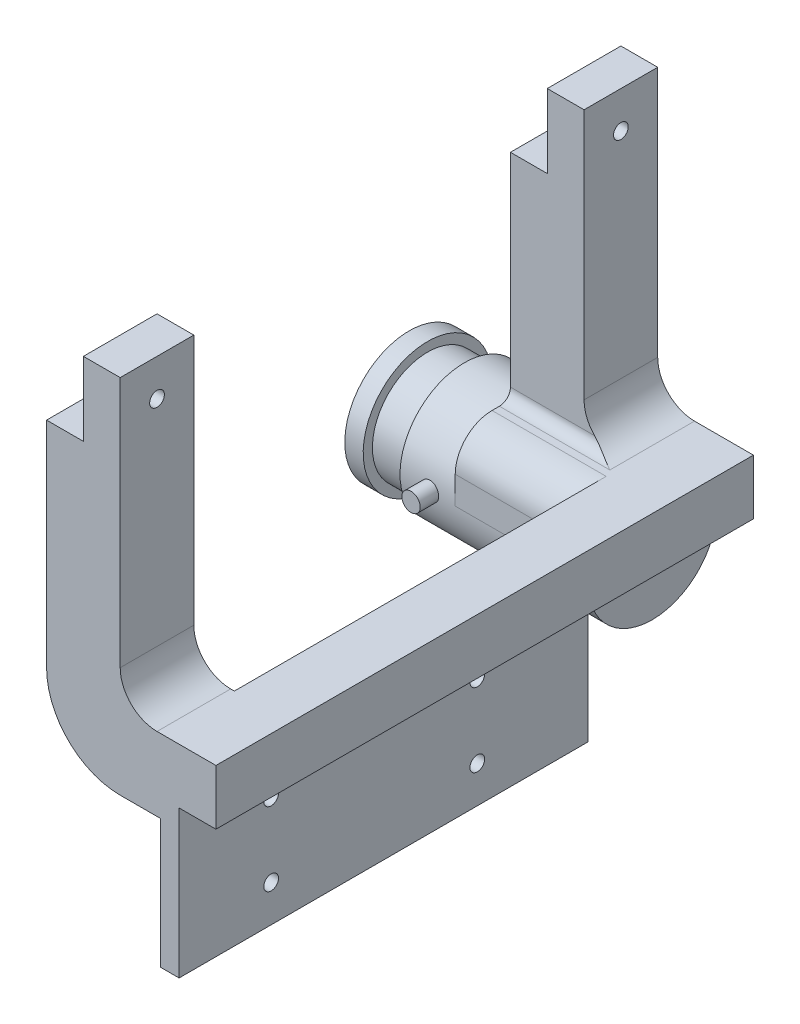
from build123d import *

# Parameters (mm, degrees)
BOSS_EXTRUDE3_DEPTH              = 10
SKETCH8_W                        = 146
SKETCH8_H                        = 15
BOSS_EXTRUDE6_DEPTH              = 5
SKETCH9_W                        = 5
SKETCH9_H                        = 146
BOSS_EXTRUDE7_DEPTH              = 20
BOSS_EXTRUDE8_DEPTH              = 20
SKETCH17_W                       = 20
SKETCH17_H                       = 20
CUT_EXTRUDE4_DEPTH               = 10
SKETCH18_R                       = 2
CUT_EXTRUDE5_DEPTH               = 10
SKETCH20_W                       = 35
SKETCH20_H                       = 35
BOSS_EXTRUDE9_DEPTH              = 31
SKETCH21_R                       = 17.5
BOSS_EXTRUDE10_DEPTH             = 30
CUT_EXTRUDE6_DEPTH               = 31
FILLET1_R                        = 3
SKETCH26_R                       = 17.5
SKETCH26_R_2                     = 15
CUT_EXTRUDE9_DEPTH               = 10
FILLET2_R                        = 10
SKETCH27_W                       = 5
SKETCH27_H                       = 146
BOSS_EXTRUDE11_DEPTH             = 20
SKETCH28_W                       = 10
SKETCH28_H                       = 126
CUT_EXTRUDE10_DEPTH              = 10
SKETCH29_R                       = 2
CUT_EXTRUDE11_DEPTH              = 5
CUT_EXTRUDE12_DEPTH              = 5
SKETCH31_R                       = 2.5
BOSS_EXTRUDE12_DEPTH             = 5
BOSS_EXTRUDE12_DIRECTION_2_REACH = 37


with BuildPart() as part:
    # Sketch4 → Boss-Extrude3 (new body)
    with BuildSketch(Plane(origin=(0, 0, 0), x_dir=(0, 0, -1), z_dir=(1, 0, 0))):
        Polygon((0, 10), (-10, 10), (-10, 25), (136, 25), (136, 10), (126, 10), (126, 0), (0, 0), align=None)
    extrude(amount=BOSS_EXTRUDE3_DEPTH)

    # Sketch8 → Boss-Extrude6 (add)
    with BuildSketch(Plane.ZY):
        with Locations((-63, 17.5)):
            Rectangle(SKETCH8_W, SKETCH8_H)
    extrude(amount=BOSS_EXTRUDE6_DEPTH)

    # Sketch9 → Boss-Extrude7 (add)
    with BuildSketch(Plane.XZ.offset(-10)):
        with Locations((-2.5, -63)):
            Rectangle(SKETCH9_W, SKETCH9_H)
    extrude(amount=BOSS_EXTRUDE7_DEPTH)

    # Sketch14 → Boss-Extrude8 (add)
    with BuildSketch(Plane.XY.offset(10)):
        with BuildLine():
            Line((-5, 25), (-6, 25))
            ThreePointArc((-6, 25), (-13.071067812, 27.928932188), (-16, 35))
            Line((-16, 35), (-16, 83.24))
            Line((-16, 83.24), (-16, 103.24))
            Line((-16, 103.24), (-36, 103.24))
            Line((-36, 103.24), (-36, 93.24))
            Line((-36, 93.24), (-36, 83.24))
            Line((-36, 83.24), (-36, 25))
            ThreePointArc((-36, 25), (-30.142135624, 10.857864376), (-16, 5))
            Line((-16, 5), (-5, 5))
            Line((-5, 5), (-5, 25))
        make_face()
    boss_extrude8 = extrude(amount=-BOSS_EXTRUDE8_DEPTH)

    # Sketch17 → Cut-Extrude4 (cut)
    with BuildSketch(Plane.ZY.offset(36)):
        with Locations((0, 93.24)):
            Rectangle(SKETCH17_W, SKETCH17_H)
    cut_extrude4 = extrude(amount=-CUT_EXTRUDE4_DEPTH, mode=Mode.SUBTRACT)

    # Sketch18 → Cut-Extrude5 (cut)
    with BuildSketch(Plane.ZY.offset(26)):
        with Locations((0, 93.24)):
            Circle(SKETCH18_R)
    cut_extrude5 = extrude(amount=-CUT_EXTRUDE5_DEPTH, mode=Mode.SUBTRACT)

    # Mirror2: Boss-Extrude8, Cut-Extrude4, Cut-Extrude5 across plane
    add(boss_extrude8.mirror(Plane.XY.offset(-63)))
    add(cut_extrude4.mirror(Plane.XY.offset(-63)), mode=Mode.SUBTRACT)
    add(cut_extrude5.mirror(Plane.XY.offset(-63)), mode=Mode.SUBTRACT)

    # Sketch20 → Boss-Extrude9 (add)
    with BuildSketch(Plane.ZY.offset(36)):
        with Locations((-118.5, 7.5)):
            Rectangle(SKETCH20_W, SKETCH20_H)
    extrude(amount=-BOSS_EXTRUDE9_DEPTH)

    # Sketch21 → Boss-Extrude10 (add)
    with BuildSketch(Plane.ZY.offset(36)):
        with Locations((-118.5, 7.5)):
            Circle(SKETCH21_R)
    extrude(amount=BOSS_EXTRUDE10_DEPTH)

    # Sketch22 → Cut-Extrude6 (cut)
    with BuildSketch(Plane.ZY.offset(36)):
        with BuildLine():
            Line((-136, 7.5), (-136, -14.77740031))
            Line((-136, -14.77740031), (-101, -14.77740031))
            Line((-101, -14.77740031), (-101, 7.5))
            ThreePointArc((-101, 7.5), (-118.5, -10), (-136, 7.5))
        make_face()
    extrude(amount=-CUT_EXTRUDE6_DEPTH, mode=Mode.SUBTRACT)

    # Fillet1
    fillet1_edges = [part.edges().sort_by_distance(p)[0] for p in [
        (-21, 25, -116),
    ]]
    fillet(fillet1_edges, radius=FILLET1_R)

    # Sketch26 → Cut-Extrude9 (cut)
    with BuildSketch(Plane.ZY.offset(51)):
        with Locations((-118.5, 7.5)):
            Circle(SKETCH26_R)
        with Locations((-118.5, 7.5)):
            Circle(SKETCH26_R_2, mode=Mode.SUBTRACT)
    extrude(amount=CUT_EXTRUDE9_DEPTH, mode=Mode.SUBTRACT)

    # Fillet2
    fillet2_edges = [part.edges().sort_by_distance(p)[0] for p in [
        (-20.5, 25, -101),
    ]]
    fillet(fillet2_edges, radius=FILLET2_R)

    # Sketch27 → Boss-Extrude11 (add)
    with BuildSketch(Plane.XZ.offset(10)):
        with Locations((-2.5, -63)):
            Rectangle(SKETCH27_W, SKETCH27_H)
    extrude(amount=BOSS_EXTRUDE11_DEPTH)

    # Sketch28 → Cut-Extrude10 (cut)
    with BuildSketch(Plane.XZ):
        with Locations((5, -63)):
            Rectangle(SKETCH28_W, SKETCH28_H)
    extrude(amount=-CUT_EXTRUDE10_DEPTH, mode=Mode.SUBTRACT)

    # Sketch29 → Cut-Extrude11 (cut)
    with BuildSketch(Plane.ZY.offset(5)):
        with Locations((-15, -20)):
            Circle(SKETCH29_R)
        with Locations((-71, -20)):
            Circle(SKETCH29_R)
        with Locations((-15, 0)):
            Circle(SKETCH29_R)
        with Locations((-71, 0)):
            Circle(SKETCH29_R)
    extrude(amount=-CUT_EXTRUDE11_DEPTH, mode=Mode.SUBTRACT)

    # Sketch30 → Cut-Extrude12 (cut)
    with BuildSketch(Plane.ZY.offset(5)):
        with BuildLine():
            Line((-136, 7.5), (-136, -30))
            Line((-136, -30), (-101, -30))
            Line((-101, -30), (-101, 7.5))
            ThreePointArc((-101, 7.5), (-118.5, -10), (-136, 7.5))
        make_face()
    extrude(amount=-CUT_EXTRUDE12_DEPTH, mode=Mode.SUBTRACT)


with BuildPart() as body_2:
    # Sketch31 → Boss-Extrude12 (new body)
    with BuildSketch(Plane.XY.offset(-101)):
        with Locations((-43, 7.5)):
            Circle(SKETCH31_R)
    extrude(amount=BOSS_EXTRUDE12_DEPTH)


    # Sketch31 → Boss-Extrude12 direction 2 (add, up to next)
    with BuildSketch(Plane.XY.offset(-101), mode=Mode.PRIVATE) as boss_extrude12_direction_2_sk1:
        with Locations((-43, 7.5)):
            Circle(SKETCH31_R)
    boss_extrude12_direction_2_tool1 = extrude(boss_extrude12_direction_2_sk1.sketch, amount=-BOSS_EXTRUDE12_DIRECTION_2_REACH, mode=Mode.PRIVATE) - part.part
    add(boss_extrude12_direction_2_tool1.solids().sort_by_distance((-43, 7.5, -101))[0])
    add(boss_extrude12_direction_2_tool1.solids().sort_by_distance((-43, 7.5, -101))[1])


solid = Compound([part.part, body_2.part])
